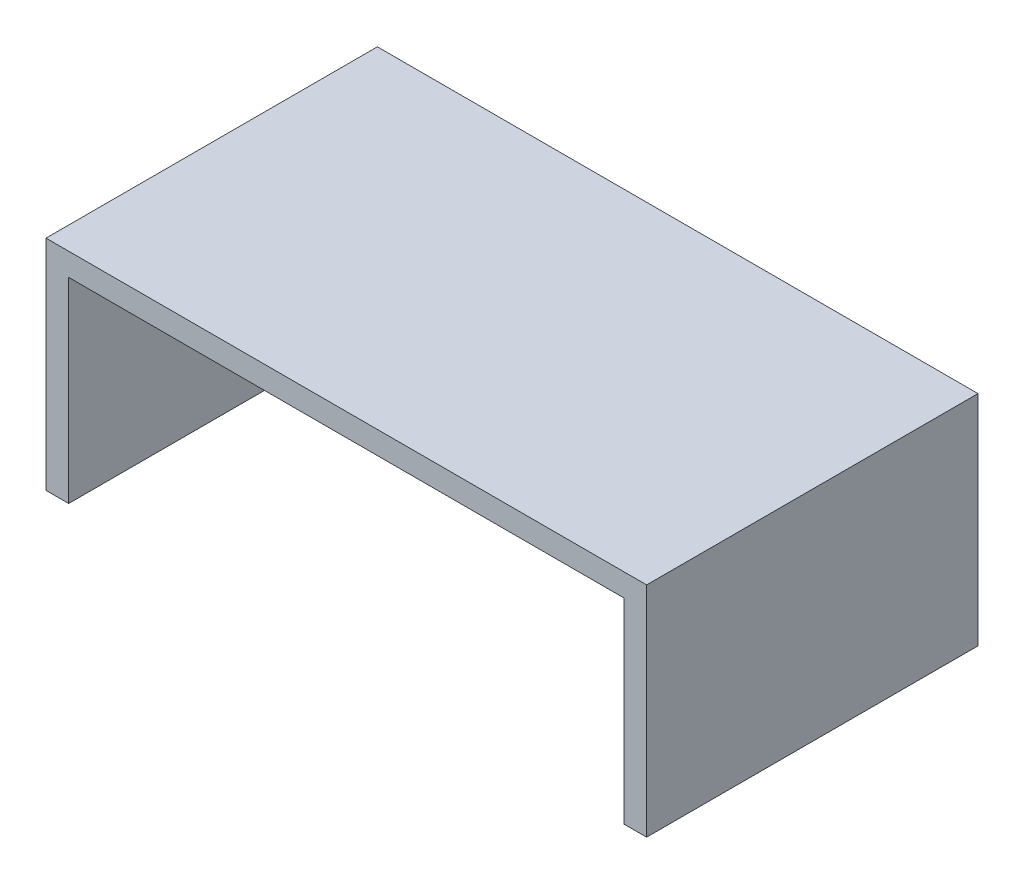
from build123d import *

# Parameters (mm, degrees)
SKETCH_1_W          = 132.5
SKETCH_1_H          = 73.1
EXTRUDE_1_DEPTH     = 48.2
SKETCH_3_W          = 122.5
SKETCH_3_H          = 43.2
CUT_EXTRUDE_1_DEPTH = 68.1
SKETCH_6_W          = 20
SKETCH_6_H          = 10
CUT_EXTRUDE_2_DEPTH = 5


with BuildPart() as part:
    # 草圖1 → 填料-伸長1 (new body)
    with BuildSketch(Plane(origin=(0, 0, 0), x_dir=(1, 0, 0), z_dir=(0, 1, 0))):
        Rectangle(SKETCH_1_W, SKETCH_1_H)
    extrude(amount=EXTRUDE_1_DEPTH)

    # 草圖3 → 除料-伸長1 (cut)
    with BuildSketch(Plane.XY.offset(36.55)):
        with Locations((0, 21.6)):
            Rectangle(SKETCH_3_W, SKETCH_3_H)
    extrude(amount=-CUT_EXTRUDE_1_DEPTH, mode=Mode.SUBTRACT)

    # 草圖6 → 除料-伸長2 (cut)
    with BuildSketch(Plane.ZY.offset(66.25)):
        with Locations((0, 38.2)):
            Rectangle(SKETCH_6_W, SKETCH_6_H)
    extrude(amount=-CUT_EXTRUDE_2_DEPTH, mode=Mode.SUBTRACT)


solid = part.part
